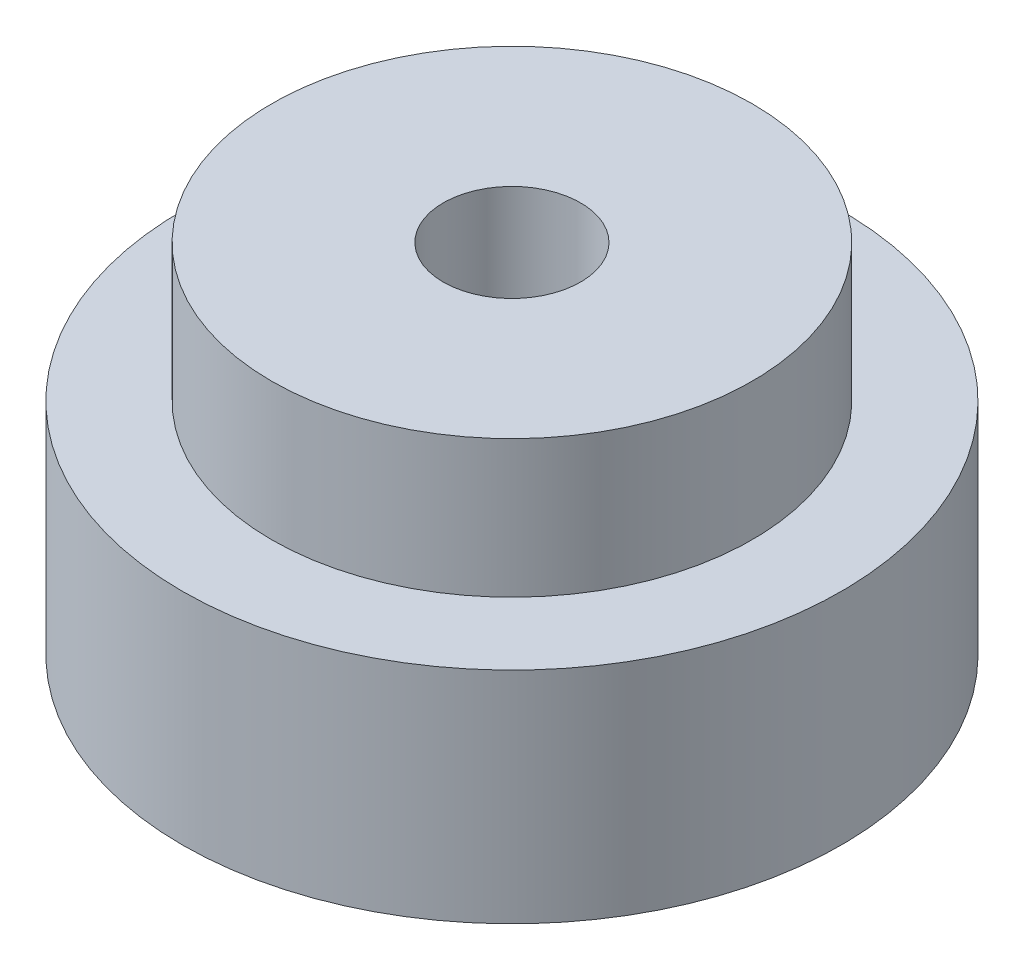
from build123d import *

# Parameters (mm, degrees)
SKETCH1_R           = 24
BOSS_EXTRUDE1_DEPTH = 16
SKETCH2_R           = 17.5
BOSS_EXTRUDE2_DEPTH = 10
SKETCH3_R           = 5
CUT_EXTRUDE1_DEPTH  = 26


with BuildPart() as part:
    # Sketch1 → Boss-Extrude1 (new body)
    with BuildSketch(Plane(origin=(0, 0, 0), x_dir=(1, 0, 0), z_dir=(0, 1, 0))):
        Circle(SKETCH1_R)
    extrude(amount=BOSS_EXTRUDE1_DEPTH)

    # Sketch2 → Boss-Extrude2 (add)
    with BuildSketch(Plane(origin=(0, 16, 0), x_dir=(1, 0, 0), z_dir=(0, 1, 0))):
        Circle(SKETCH2_R)
    extrude(amount=BOSS_EXTRUDE2_DEPTH)

    # Sketch3 → Cut-Extrude1 (cut)
    with BuildSketch(Plane(origin=(0, 26, 0), x_dir=(1, 0, 0), z_dir=(0, 1, 0))):
        Circle(SKETCH3_R)
    extrude(amount=-CUT_EXTRUDE1_DEPTH, mode=Mode.SUBTRACT)


solid = part.part
